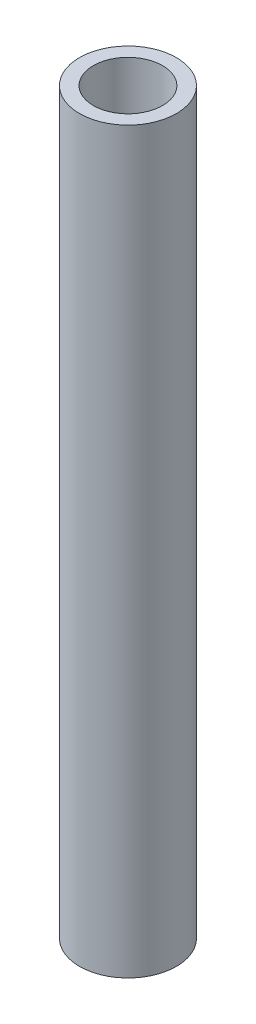
from build123d import *

# Parameters (mm, degrees)
SKETCH5_R           = 13.335
SKETCH5_R_2         = 9.525
BOSS_EXTRUDE1_DEPTH = 203.2


with BuildPart() as part:
    # Sketch5 → Boss-Extrude1 (new body)
    with BuildSketch(Plane(origin=(0, 0, 0), x_dir=(1, 0, 0), z_dir=(0, 1, 0))):
        Circle(SKETCH5_R)
        Circle(SKETCH5_R_2, mode=Mode.SUBTRACT)
    extrude(amount=BOSS_EXTRUDE1_DEPTH)


solid = part.part
